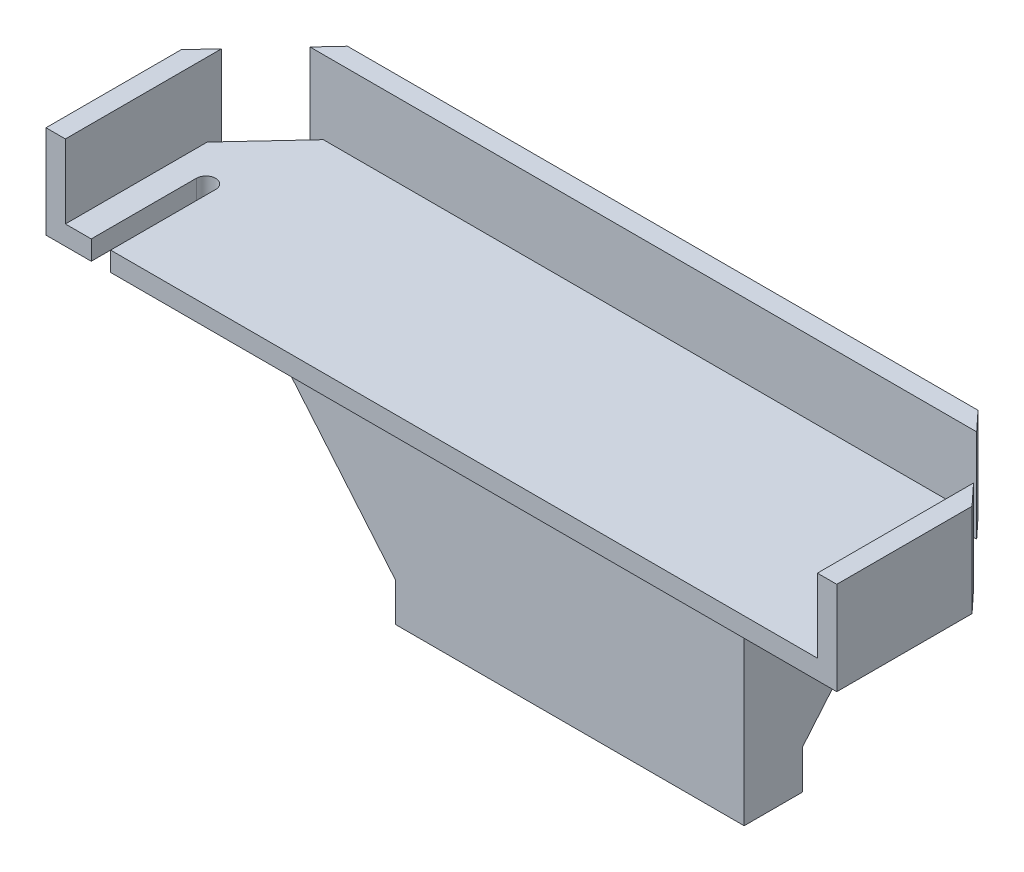
from build123d import *

# Parameters (mm, degrees)
SKETCH1_W             = 18
SKETCH1_H             = 3
BOSS_EXTRUDE1_DEPTH   = 9
BOSS_EXTRUDE2_DEPTH   = 4.8
CUT_EXTRUDE2_DEPTH    = 3.8
CUT_EXTRUDE3_DEPTH    = 6
CUT_EXTRUDE4_DEPTH    = 6.9
CUT_EXTRUDE5_DEPTH    = 4.5
SKETCH9_R             = 1
CUT_EXTRUDE6_DEPTH    = 4.5
SKETCH12_W            = 40.8
SKETCH12_H            = 4.8
CUT_EXTRUDE8_DEPTH    = 1.5
CHAMFER9_SIZE         = 7
CHAMFER9_SIZE2        = 5.873697418
CHAMFER9_PART_2_SIZE  = 7
CHAMFER9_PART_2_SIZE2 = 5.873697418


with BuildPart() as part:
    # Sketch1 → Boss-Extrude1 (new body)
    with BuildSketch(Plane(origin=(0, 0, 0), x_dir=(1, 0, 0), z_dir=(0, 1, 0))):
        with Locations((6, 0)):
            Rectangle(SKETCH1_W, SKETCH1_H)
    extrude(amount=BOSS_EXTRUDE1_DEPTH)

    # Sketch4 → Boss-Extrude2 (add)
    with BuildSketch(Plane(origin=(0, 9, 0), x_dir=(1, 0, 0), z_dir=(0, 1, 0))):
        Polygon((-16.265306784, 9.3), (16.265306784, 9.3), (20.4, 4.858031992), (20.4, -4.620102593), (-20.4, -4.620102593), (-20.4, 4.858031992), align=None)
    extrude(amount=BOSS_EXTRUDE2_DEPTH)

    # Sketch5 → Cut-Extrude2 (cut)
    with BuildSketch(Plane(origin=(0, 13.8, 0), x_dir=(1, 0, 0), z_dir=(0, 1, 0))):
        Polygon((16.513043846, 8.3), (-16.513043846, 8.3), (-19.4, 5.198496162), (-19.4, -3.620102593), (19.4, -3.620102593), (19.4, 5.198496162), align=None)
    extrude(amount=-CUT_EXTRUDE2_DEPTH, mode=Mode.SUBTRACT)

    # Sketch5_3 → Cut-Extrude3 (cut)
    with BuildSketch(Plane(origin=(0, 13.8, 0), x_dir=(1, 0, 0), z_dir=(0, 1, 0))):
        Polygon((20.4, -3.620102593), (19.4, -3.620102593), (-19.4, -3.620102593), (-20.4, -3.620102593), (-20.4, -4.620102593), (20.4, -4.620102593), align=None)
    extrude(amount=-CUT_EXTRUDE3_DEPTH, mode=Mode.SUBTRACT)

    # Sketch6 → Cut-Extrude4 (cut)
    with BuildSketch(Plane(origin=(0, 13.8, 0), x_dir=(1, 0, 0), z_dir=(0, 1, 0))):
        Polygon((-19.4, 5.198496162), (-19.4, 8.3), (-16.513043846, 8.3), align=None)
        Polygon((16.513043846, 8.3), (19.4, 5.198496162), (19.4, 8.3), align=None)
    extrude(amount=-CUT_EXTRUDE4_DEPTH, mode=Mode.SUBTRACT)

    # Sketch8 → Cut-Extrude5 (cut)
    with BuildSketch(Plane(origin=(0, 10, 0), x_dir=(1, 0, 0), z_dir=(0, 1, 0))):
        with BuildLine():
            Line((-17.065370438, 3.3), (-17.065370438, -4.992630539))
            ThreePointArc((-17.065370438, -4.992630539), (-17.565370438, -5.492630539), (-18.065370438, -4.992630539))
            Line((-18.065370438, -4.992630539), (-18.065370438, 3.3))
            ThreePointArc((-18.065370438, 3.3), (-17.565370438, 3.8), (-17.065370438, 3.3))
        make_face()
    extrude(amount=-CUT_EXTRUDE5_DEPTH, mode=Mode.SUBTRACT)

    # Sketch9 → Cut-Extrude6 (cut)
    with BuildSketch(Plane.XZ):
        with Locations((2.915469811, 0)):
            Circle(SKETCH9_R)
        with Locations((7.084530189, 0)):
            Circle(SKETCH9_R)
    extrude(amount=-CUT_EXTRUDE6_DEPTH, mode=Mode.SUBTRACT)

    # Sketch12 → Cut-Extrude8 (cut)
    with BuildSketch(Plane.XY.offset(3.620102593)):
        with Locations((0, 11.4)):
            Rectangle(SKETCH12_W, SKETCH12_H)
    extrude(amount=-CUT_EXTRUDE8_DEPTH, mode=Mode.SUBTRACT)

    # Chamfer9
    chamfer9_edges = [part.edges().sort_by_distance(p)[0] for p in [
        (6, 9, -1.5),
    ]]
    chamfer9_side = [part.faces().sort_by_distance(p)[0] for p in [
        (6, 4.5, -1.5),
    ]]
    chamfer(chamfer9_edges, length=CHAMFER9_SIZE, length2=CHAMFER9_SIZE2, reference=chamfer9_side[0])

    # Chamfer9 part 2
    chamfer9_part_2_edges = [part.edges().sort_by_distance(p)[0] for p in [
        (-3, 9, 0),
    ]]
    chamfer9_part_2_side = [part.faces().sort_by_distance(p)[0] for p in [
        (-3, 4.5, 0),
    ]]
    chamfer(chamfer9_part_2_edges, length=CHAMFER9_PART_2_SIZE, length2=CHAMFER9_PART_2_SIZE2, reference=chamfer9_part_2_side[0])


solid = part.part
